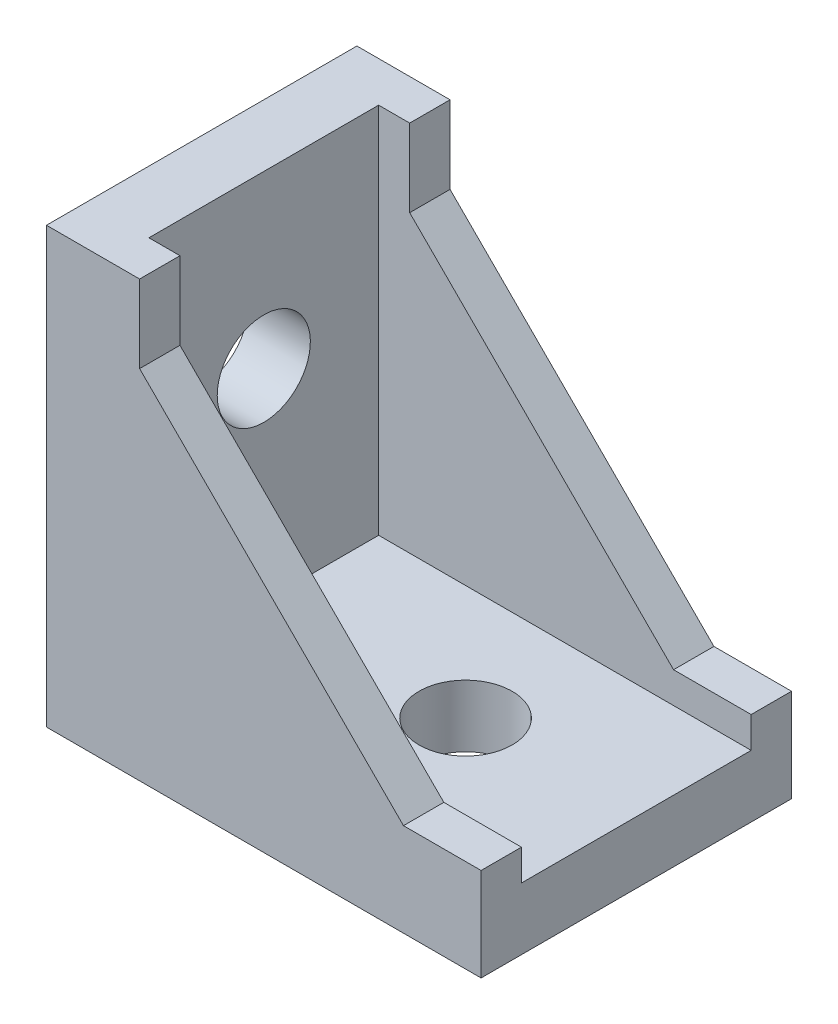
from build123d import *

# Parameters (mm, degrees)
EXTRUDE_1_DEPTH     = 20
EXTRUDE_2_DEPTH     = 2.6
SKETCH_3_W          = 6
SKETCH_3_H          = 2
EXTRUDE_3_DEPTH     = 1.5
SKETCH_4_R          = 3
CUT_EXTRUDE_1_DEPTH = 4


with BuildPart() as part:
    # 草图1 → 凸台-拉伸1 (new body)
    with BuildSketch(Plane.XY):
        Polygon((0, 0), (0, 28), (4, 28), (4, 4), (28, 4), (28, 0), align=None)
    extrude(amount=EXTRUDE_1_DEPTH)

    # 草图2 → 凸台-拉伸2 (add)
    with BuildSketch(Plane.XY.offset(20)):
        Polygon((4, 28), (6, 28), (6, 23), (23, 6), (28, 6), (28, 4), (4, 4), align=None)
    extrude_2 = extrude(amount=-EXTRUDE_2_DEPTH)

    # 镜向1: 凸台-拉伸2 across plane
    add(extrude_2.mirror(Plane(origin=(0, 0, 10), x_dir=(1, 0, 0), z_dir=(0, 0, -1))))

    # 草图3 → 凸台-拉伸3 (add)
    with BuildSketch(Plane.ZY):
        with Locations((10, 25)):
            Rectangle(SKETCH_3_W, SKETCH_3_H)
        with Locations((10, 3)):
            Rectangle(SKETCH_3_W, SKETCH_3_H)
    extrude_3 = extrude(amount=EXTRUDE_3_DEPTH)

    # 镜向2: 凸台-拉伸3 across plane
    add(extrude_3.mirror(Plane(origin=(0, 0, 0), x_dir=(0, 0, 1), z_dir=(-0.707106781, 0.707106781, 0))))

    # 草图4 → 切除-拉伸1 (cut)
    with BuildSketch(Plane.ZY):
        with Locations((10, 17)):
            Circle(SKETCH_4_R)
    cut_extrude_1 = extrude(amount=-CUT_EXTRUDE_1_DEPTH, mode=Mode.SUBTRACT)

    # 镜向3: 切除-拉伸1 across plane
    add(cut_extrude_1.mirror(Plane(origin=(0, 0, 0), x_dir=(0, 0, 1), z_dir=(-0.707106781, 0.707106781, 0))), mode=Mode.SUBTRACT)


solid = part.part
